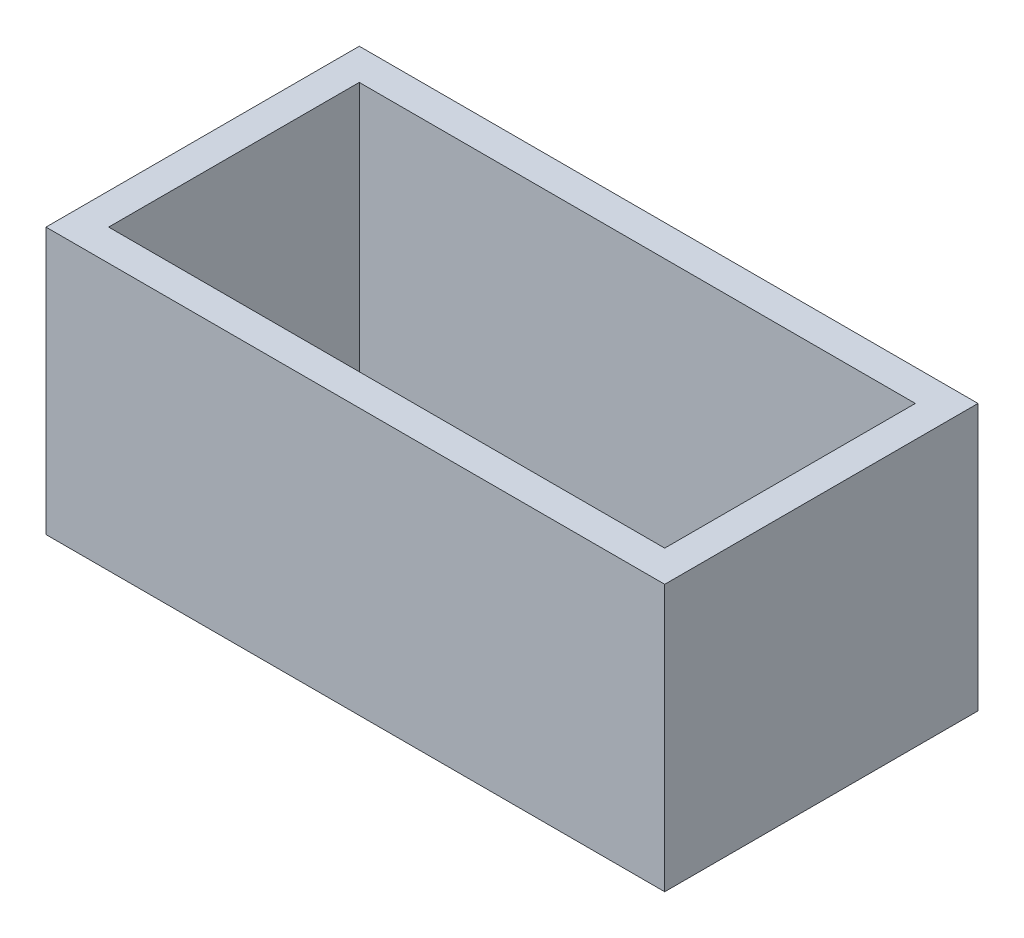
from build123d import *

# Parameters (mm, degrees)
SKETCH1_W           = 39.5
SKETCH1_H           = 20
SKETCH1_W_2         = 35.5
SKETCH1_H_2         = 16
BOSS_EXTRUDE1_DEPTH = 17


with BuildPart() as part:
    # Sketch1 → Boss-Extrude1 (new body)
    with BuildSketch(Plane(origin=(0, 0, 0), x_dir=(1, 0, 0), z_dir=(0, 1, 0))):
        Rectangle(SKETCH1_W, SKETCH1_H)
        Rectangle(SKETCH1_W_2, SKETCH1_H_2, mode=Mode.SUBTRACT)
    extrude(amount=BOSS_EXTRUDE1_DEPTH)


solid = part.part
